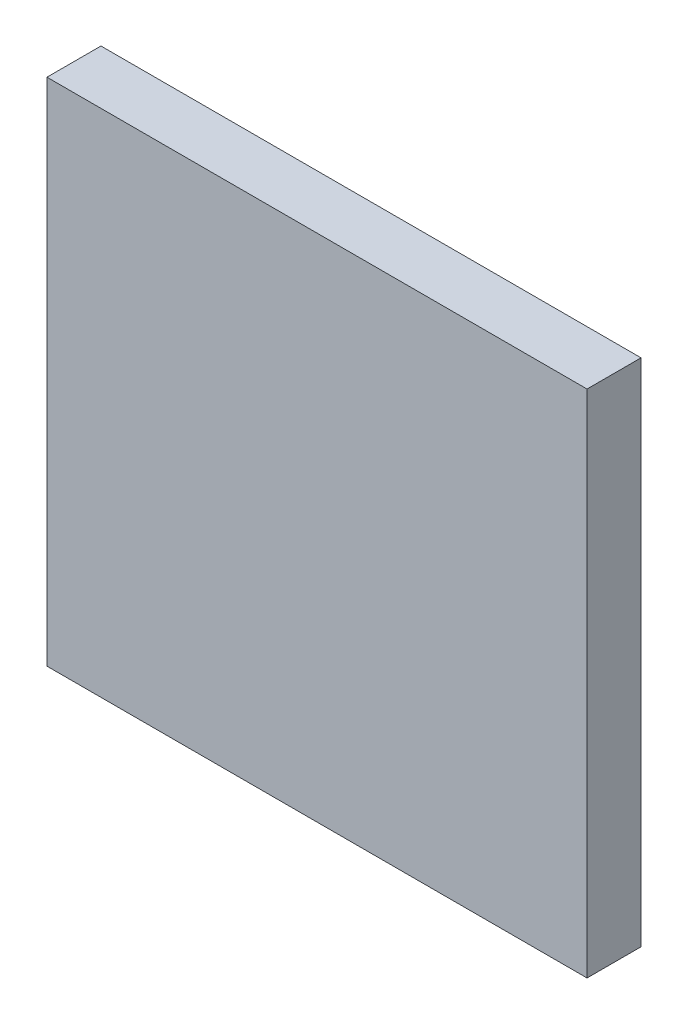
from build123d import *

# Parameters (mm, degrees)
SKETCH_1_W      = 180
SKETCH_1_H      = 170
EXTRUDE_1_DEPTH = 18


with BuildPart() as part:
    # Эскиз1 → Бобышка-Вытянуть1 (new body)
    with BuildSketch(Plane.XY):
        with Locations((87.747935181, 74.865708313)):
            Rectangle(SKETCH_1_W, SKETCH_1_H)
    extrude(amount=EXTRUDE_1_DEPTH)


solid = part.part
